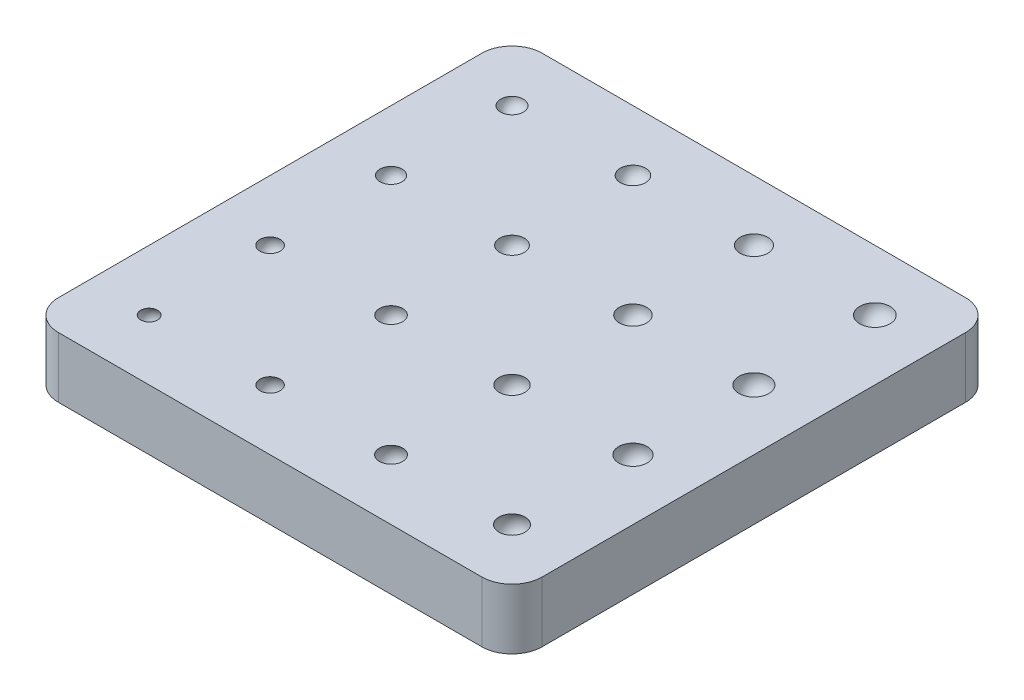
from build123d import *

# Parameters (mm, degrees)
SKETCH1_W           = 101.6
SKETCH1_H           = 101.6
BOSS_EXTRUDE1_DEPTH = 12.7
FILLET1_R           = 6.35


with BuildPart() as part:
    # Sketch1 → Boss-Extrude1 (new body)
    with BuildSketch(Plane(origin=(0, 0, 0), x_dir=(1, 0, 0), z_dir=(0, 1, 0))):
        Rectangle(SKETCH1_W, SKETCH1_H)
    extrude(amount=BOSS_EXTRUDE1_DEPTH)

    # Sketch3 → Cut-Revolve2 (revolve, cut)
    with BuildSketch(Plane.ZY.offset(38.1)):
        with BuildLine():
            Line((-38.1, 15.08125), (-38.1, 10.31875))
            ThreePointArc((-38.1, 10.31875), (-40.48125, 12.7), (-38.1, 15.08125))
        make_face()
    revolve(axis=Axis((-38.1, 13.335, -38.1), (0, -1, 0)), mode=Mode.SUBTRACT)

    # Sketch4 → Cut-Revolve3 (revolve, cut)
    with BuildSketch(Plane.ZY.offset(38.1)):
        with BuildLine():
            Line((38.1, 13.49375), (38.1, 8.73125))
            ThreePointArc((38.1, 8.73125), (40.48125, 11.1125), (38.1, 13.49375))
        make_face()
    revolve(axis=Axis((-38.1, -0.635, 38.1), (0, 1, 0)), mode=Mode.SUBTRACT)

    # Sketch5 → Cut-Revolve4 (revolve, cut)
    with BuildSketch(Plane.ZY.offset(38.1)):
        with BuildLine():
            Line((12.7, 14.022916667), (12.7, 9.260416667))
            ThreePointArc((12.7, 9.260416667), (15.08125, 11.641666667), (12.7, 14.022916667))
        make_face()
    revolve(axis=Axis((-38.1, -0.635, 12.7), (0, 1, 0)), mode=Mode.SUBTRACT)

    # Sketch6 → Cut-Revolve5 (revolve, cut)
    with BuildSketch(Plane.ZY.offset(38.1)):
        with BuildLine():
            Line((-12.7, 14.552083333), (-12.7, 9.789583333))
            ThreePointArc((-12.7, 9.789583333), (-10.31875, 12.170833333), (-12.7, 14.552083333))
        make_face()
    revolve(axis=Axis((-38.1, -0.635, -12.7), (0, 1, 0)), mode=Mode.SUBTRACT)

    # Sketch7 → Cut-Revolve6 (revolve, cut)
    with BuildSketch(Plane.XY.offset(-38.1)):
        with BuildLine():
            Line((-12.7, 15.345833329), (-12.7, 10.054166671))
            ThreePointArc((-12.7, 10.054166671), (-15.345833329, 12.7), (-12.7, 15.345833329))
        make_face()
    revolve(axis=Axis((-12.7, 13.335, -38.1), (0, -1, 0)), mode=Mode.SUBTRACT)

    # Sketch8 → Cut-Revolve7 (revolve, cut)
    with BuildSketch(Plane.XY.offset(-38.1)):
        with BuildLine():
            Line((12.7, 15.610416667), (12.7, 9.789583333))
            ThreePointArc((12.7, 9.789583333), (9.789583333, 12.7), (12.7, 15.610416667))
        make_face()
    revolve(axis=Axis((12.7, 13.335, -38.1), (0, -1, 0)), mode=Mode.SUBTRACT)

    # Sketch9 → Cut-Revolve8 (revolve, cut)
    with BuildSketch(Plane.XY.offset(-38.1)):
        with BuildLine():
            Line((38.1, 15.875), (38.1, 9.525))
            ThreePointArc((38.1, 9.525), (34.925, 12.7), (38.1, 15.875))
        make_face()
    revolve(axis=Axis((38.1, 13.335, -38.1), (0, -1, 0)), mode=Mode.SUBTRACT)

    # Sketch10 → Cut-Revolve9 (revolve, cut)
    with BuildSketch(Plane.XY.offset(-12.7)):
        with BuildLine():
            Line((-12.7, 14.816666666), (-12.7, 9.525))
            ThreePointArc((-12.7, 9.525), (-10.054166667, 12.170833333), (-12.7, 14.816666666))
        make_face()
    revolve(axis=Axis((-12.7, -0.635, -12.7), (0, 1, 0)), mode=Mode.SUBTRACT)

    # Sketch11 → Cut-Revolve10 (revolve, cut)
    with BuildSketch(Plane.XY.offset(-12.7)):
        with BuildLine():
            Line((12.7, 15.08125), (12.7, 9.260416667))
            ThreePointArc((12.7, 9.260416667), (15.610416667, 12.170833333), (12.7, 15.08125))
        make_face()
    revolve(axis=Axis((12.7, -0.635, -12.7), (0, 1, 0)), mode=Mode.SUBTRACT)

    # Sketch12 → Cut-Revolve11 (revolve, cut)
    with BuildSketch(Plane.XY.offset(-12.7)):
        with BuildLine():
            Line((38.1, 15.345833333), (38.1, 8.995833333))
            ThreePointArc((38.1, 8.995833333), (41.275, 12.170833333), (38.1, 15.345833333))
        make_face()
    revolve(axis=Axis((38.1, 13.335, -12.7), (0, -1, 0)), mode=Mode.SUBTRACT)

    # Sketch14 → Cut-Revolve12 (revolve, cut)
    with BuildSketch(Plane.XY.offset(12.7)):
        with BuildLine():
            Line((-12.7, 14.2875), (-12.7, 8.995833333))
            ThreePointArc((-12.7, 8.995833333), (-10.054166667, 11.641666667), (-12.7, 14.2875))
        make_face()
    revolve(axis=Axis((-12.7, 13.335, 12.7), (0, -1, 0)), mode=Mode.SUBTRACT)

    # Sketch15 → Cut-Revolve13 (revolve, cut)
    with BuildSketch(Plane.XY.offset(12.7)):
        with BuildLine():
            Line((12.7, 14.552083333), (12.7, 8.73125))
            ThreePointArc((12.7, 8.73125), (15.610416667, 11.641666667), (12.7, 14.552083333))
        make_face()
    revolve(axis=Axis((12.7, -0.635, 12.7), (0, 1, 0)), mode=Mode.SUBTRACT)

    # Sketch16 → Cut-Revolve14 (revolve, cut)
    with BuildSketch(Plane.XY.offset(12.7)):
        with BuildLine():
            Line((38.1, 14.816666667), (38.1, 8.466666667))
            ThreePointArc((38.1, 8.466666667), (41.275, 11.641666667), (38.1, 14.816666667))
        make_face()
    revolve(axis=Axis((38.1, -0.635, 12.7), (0, 1, 0)), mode=Mode.SUBTRACT)

    # Sketch17 → Cut-Revolve15 (revolve, cut)
    with BuildSketch(Plane.XY.offset(38.1)):
        with BuildLine():
            Line((-12.7, 13.758333333), (-12.7, 8.466666667))
            ThreePointArc((-12.7, 8.466666667), (-10.054166667, 11.1125), (-12.7, 13.758333333))
        make_face()
    revolve(axis=Axis((-12.7, 13.335, 38.1), (0, -1, 0)), mode=Mode.SUBTRACT)

    # Sketch18 → Cut-Revolve16 (revolve, cut)
    with BuildSketch(Plane.XY.offset(38.1)):
        with BuildLine():
            Line((12.7, 14.022916667), (12.7, 8.202083333))
            ThreePointArc((12.7, 8.202083333), (15.610416667, 11.1125), (12.7, 14.022916667))
        make_face()
    revolve(axis=Axis((12.7, 13.335, 38.1), (0, -1, 0)), mode=Mode.SUBTRACT)

    # Sketch19 → Cut-Revolve17 (revolve, cut)
    with BuildSketch(Plane.XY.offset(38.1)):
        with BuildLine():
            Line((38.1, 14.2875), (38.1, 7.9375))
            ThreePointArc((38.1, 7.9375), (41.275, 11.1125), (38.1, 14.2875))
        make_face()
    revolve(axis=Axis((38.1, 13.335, 38.1), (0, -1, 0)), mode=Mode.SUBTRACT)

    # Fillet1
    fillet1_edges = [part.edges().sort_by_distance(p)[0] for p in [
        (50.8, 6.35, 50.8),
        (-50.8, 6.35, 50.8),
        (-50.8, 6.35, -50.8),
        (50.8, 6.35, -50.8),
    ]]
    fillet(fillet1_edges, radius=FILLET1_R)


solid = part.part
